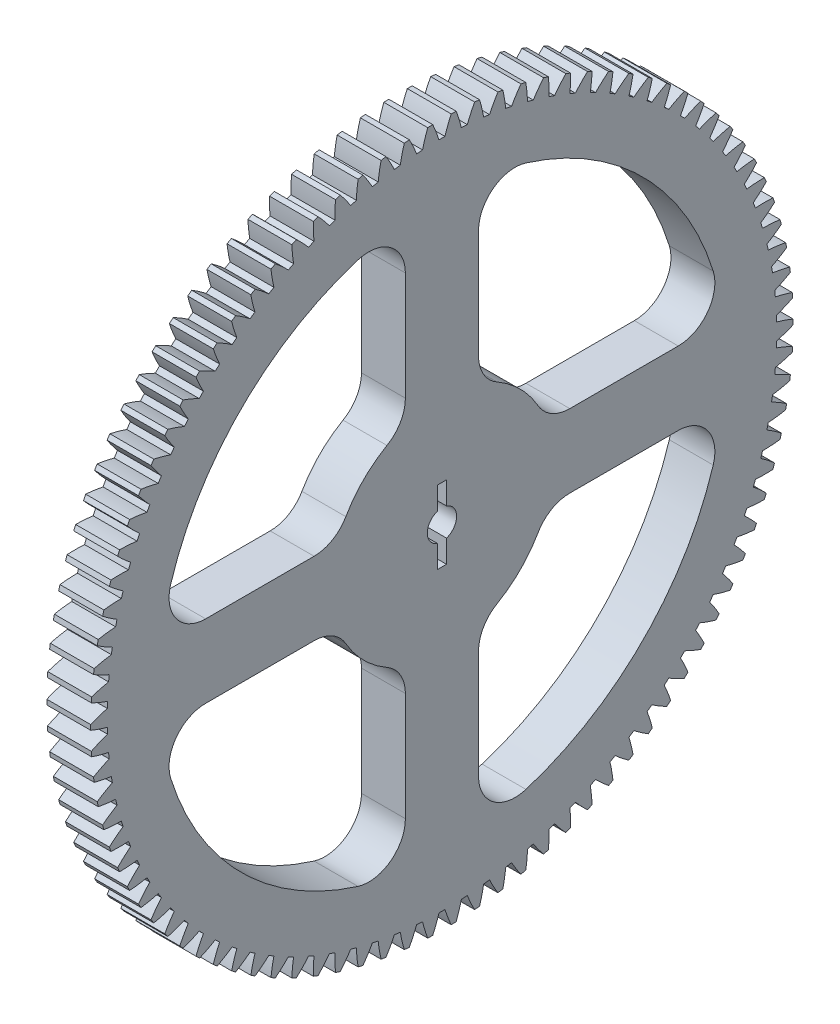
from build123d import *

# Parameters (mm, degrees)
BASPROSKE_W        = 12
BASPROSKE_H        = 96
TOOTHCUT_DEPTH     = 137.293800299
TEETHCUTS_COUNT    = 94
TEETHCUTS_ANGLE    = 356.170212766
BORSKE_R           = 2
BORE_DEPTH         = 50.0000508
SKETCH1_R          = 4
CUT_EXTRUDE1_DEPTH = 26
SKETCH2_W          = 2.5
SKETCH2_H          = 20
CUT_EXTRUDE2_DEPTH = 26


with BuildPart() as part:
    # BasProSke → Base-Revolve (revolve)
    with BuildSketch(Plane(origin=(0, 0, 0), x_dir=(1, 0, 0), z_dir=(0, 1, 0)), mode=Mode.PRIVATE) as base_revolve_sk:
        with Locations((6, 48)):
            Rectangle(BASPROSKE_W, BASPROSKE_H)
    revolve(base_revolve_sk.sketch.rotate(Axis((-10, 0, 0), (1, 0, 0)), 180), axis=Axis((-10, 0, 0), (1, 0, 0)))

    # TooCutSke → ToothCut (cut, through all)
    with BuildSketch(Plane(origin=(0, 0, 0), x_dir=(0, 0, -1), z_dir=(1, 0, 0))):
        with BuildLine():
            ThreePointArc((0.817356548, 91.495349222), (0, 91.499), (-0.817356548, 91.495349222))
            ThreePointArc((-0.817356548, 91.495349222), (-1.605474017, 93.771168145), (-2.537674532, 95.991862432))
            ThreePointArc((-2.537674532, 95.991862432), (0, 96.0254), (2.537674532, 95.991862432))
            ThreePointArc((2.537674532, 95.991862432), (1.605474017, 93.771168145), (0.817356548, 91.495349222))
        make_face()
    toothcut = extrude(amount=TOOTHCUT_DEPTH, mode=Mode.SUBTRACT)

    # TeethCuts: ToothCut ×94 about axis
    teethcuts_axis = Axis((-10, 0, 0), (1, 0, 0))
    for i in range(1, TEETHCUTS_COUNT):
        add(toothcut.rotate(teethcuts_axis, i * TEETHCUTS_ANGLE / (TEETHCUTS_COUNT - 1)), mode=Mode.SUBTRACT)

    # BorSke → Bore (cut, symmetric)
    with BuildSketch(Plane(origin=(0, 0, 0), x_dir=(0, 0, -1), z_dir=(1, 0, 0))):
        with Locations(Location((0, 0, 0), (0, 0, 180))):
            Circle(BORSKE_R)
    extrude(amount=BORE_DEPTH, both=True, mode=Mode.SUBTRACT)

    # Sketch1 → Cut-Extrude1 (cut)
    with BuildSketch(Plane(origin=(12, 0, 0), x_dir=(0, 0, -1), z_dir=(1, 0, 0))):
        Circle(SKETCH1_R)
        with BuildLine():
            Line((-34.948563123, 10), (-64.588922273, 10))
            ThreePointArc((-64.588922273, 10), (-72.638128053, 14.066174394), (-74.141438945, 22.957942736))
            ThreePointArc((-74.141438945, 22.957942736), (-54.881782513, 54.881782513), (-22.957942736, 74.141438945))
            ThreePointArc((-22.957942736, 74.141438945), (-14.066174394, 72.638128053), (-10, 64.588922273))
            Line((-10, 64.588922273), (-10, 34.948563123))
            ThreePointArc((-10, 34.948563123), (-11.349308969, 29.932035969), (-15.033108937, 26.269277831))
            ThreePointArc((-15.033108937, 26.269277831), (-21.401744346, 21.401744346), (-26.269277831, 15.033108937))
            ThreePointArc((-26.269277831, 15.033108937), (-29.932035969, 11.349308969), (-34.948563123, 10))
        make_face()
        with BuildLine():
            Line((-10, -64.588922273), (-10, -34.948563123))
            ThreePointArc((-10, -34.948563123), (-11.349308969, -29.932035969), (-15.033108937, -26.269277831))
            ThreePointArc((-15.033108937, -26.269277831), (-21.401744346, -21.401744346), (-26.269277831, -15.033108937))
            ThreePointArc((-26.269277831, -15.033108937), (-29.932035969, -11.349308969), (-34.948563123, -10))
            Line((-34.948563123, -10), (-64.588922273, -10))
            ThreePointArc((-64.588922273, -10), (-72.638128053, -14.066174394), (-74.141438945, -22.957942736))
            ThreePointArc((-74.141438945, -22.957942736), (-54.881782513, -54.881782513), (-22.957942736, -74.141438945))
            ThreePointArc((-22.957942736, -74.141438945), (-14.066174394, -72.638128053), (-10, -64.588922273))
        make_face()
        with BuildLine():
            Line((10, -64.588922273), (10, -34.948563123))
            ThreePointArc((10, -34.948563123), (11.349308969, -29.932035969), (15.033108937, -26.269277831))
            ThreePointArc((15.033108937, -26.269277831), (21.401744346, -21.401744346), (26.269277831, -15.033108937))
            ThreePointArc((26.269277831, -15.033108937), (29.932035969, -11.349308969), (34.948563123, -10))
            Line((34.948563123, -10), (64.588922273, -10))
            ThreePointArc((64.588922273, -10), (72.638128053, -14.066174394), (74.141438945, -22.957942736))
            ThreePointArc((74.141438945, -22.957942736), (54.881782513, -54.881782513), (22.957942736, -74.141438945))
            ThreePointArc((22.957942736, -74.141438945), (14.066174394, -72.638128053), (10, -64.588922273))
        make_face()
        with BuildLine():
            Line((64.588922273, 10), (34.948563123, 10))
            ThreePointArc((34.948563123, 10), (29.932035969, 11.349308969), (26.269277831, 15.033108937))
            ThreePointArc((26.269277831, 15.033108937), (21.401744346, 21.401744346), (15.033108937, 26.269277831))
            ThreePointArc((15.033108937, 26.269277831), (11.349308969, 29.932035969), (10, 34.948563123))
            Line((10, 34.948563123), (10, 64.588922273))
            ThreePointArc((10, 64.588922273), (14.066174394, 72.638128053), (22.957942736, 74.141438945))
            ThreePointArc((22.957942736, 74.141438945), (54.881782513, 54.881782513), (74.141438945, 22.957942736))
            ThreePointArc((74.141438945, 22.957942736), (72.638128053, 14.066174394), (64.588922273, 10))
        make_face()
    extrude(amount=-CUT_EXTRUDE1_DEPTH, mode=Mode.SUBTRACT)

    # Sketch2 → Cut-Extrude2 (cut)
    with BuildSketch(Plane(origin=(12, 0, 0), x_dir=(0, 0, -1), z_dir=(1, 0, 0))):
        Rectangle(SKETCH2_W, SKETCH2_H)
    extrude(amount=-CUT_EXTRUDE2_DEPTH, mode=Mode.SUBTRACT)


solid = part.part
